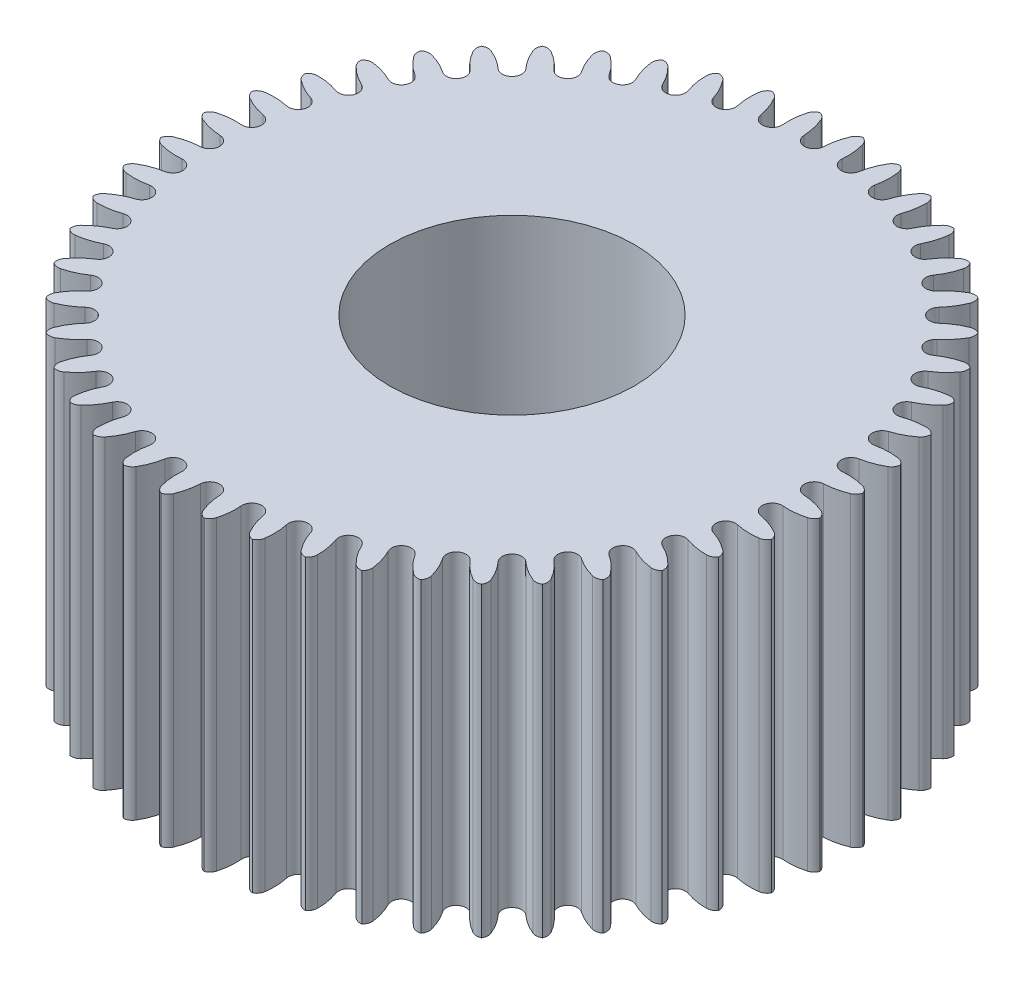
from build123d import *

# Parameters (mm, degrees)
SKETCH1_R           = 27
BOSS_EXTRUDE1_DEPTH = 25
CUT_EXTRUDE1_DEPTH  = 25
CIRPATTERN1_COUNT   = 48
SKETCH4_R           = 10
CUT_EXTRUDE3_DEPTH  = 25


with BuildPart() as part:
    # Sketch1 → Boss-Extrude1 (new body)
    with BuildSketch(Plane(origin=(0, 0, 0), x_dir=(1, 0, 0), z_dir=(0, 1, 0))):
        Circle(SKETCH1_R)
    extrude(amount=BOSS_EXTRUDE1_DEPTH)

    # Sketch3 → Cut-Extrude1 (cut)
    with BuildSketch(Plane.XZ):
        with BuildLine():
            ThreePointArc((1.210058579, -26.441299647), (0.924049006, -25.559506033), (0.799158179, -24.640939903))
            ThreePointArc((0.799158179, -24.640939903), (0, -23.877630564), (-0.799158179, -24.640939903))
            ThreePointArc((-0.799158179, -24.640939903), (-0.924049006, -25.559506033), (-1.210058579, -26.441299647))
            ThreePointArc((-1.210058579, -26.441299647), (-1.530051619, -26.810994195), (-2.00542111, -26.925420817))
            ThreePointArc((-2.00542111, -26.925420817), (-1.2e-08, -27), (2.005421085, -26.925420819))
            ThreePointArc((2.005421085, -26.925420819), (1.530051608, -26.810994189), (1.210058579, -26.441299647))
        make_face()
    cut_extrude1 = extrude(amount=-CUT_EXTRUDE1_DEPTH, mode=Mode.SUBTRACT)

    # CirPattern1: Cut-Extrude1 ×48 about axis
    cirpattern1_axis = Axis((0, 0, 0), (0, 1, 0))
    for i in range(1, CIRPATTERN1_COUNT):
        add(cut_extrude1.rotate(cirpattern1_axis, i * 360 / CIRPATTERN1_COUNT), mode=Mode.SUBTRACT)

    # Sketch4 → Cut-Extrude3 (cut)
    with BuildSketch(Plane.XZ):
        Circle(SKETCH4_R)
    extrude(amount=-CUT_EXTRUDE3_DEPTH, mode=Mode.SUBTRACT)


solid = part.part
